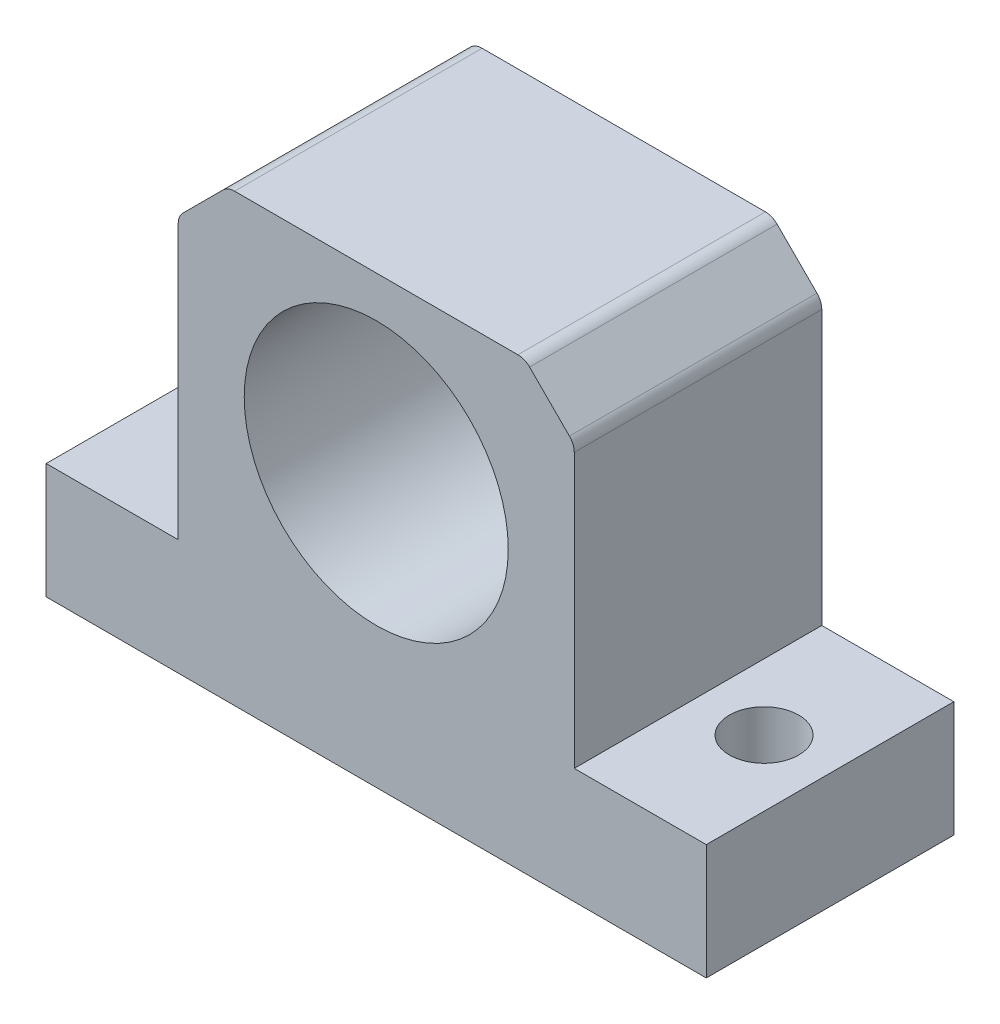
from build123d import *

# Parameters (mm, degrees)
SKETCH1_R             = 8
BOSS_EXTRUDE1_DEPTH   = 15
CHAMFER1_SIZE         = 3
SKETCH2_R             = 8
SKETCH2_R_2           = 5
BOSS_EXTRUDE2_DEPTH   = 3
M5_TAPPED_HOLE1_D     = 4.2
M5_TAPPED_HOLE1_DEPTH = 103.56
M5_TAPPED_HOLE1_TIP   = 1.2618073
FILLET1_R             = 1


with BuildPart() as part:
    # Sketch1 → Boss-Extrude1 (new body)
    with BuildSketch(Plane.XY):
        Polygon((20, 0), (-20, 0), (-20, 7), (-12, 7), (-12, 27), (12, 27), (12, 7), (20, 7), align=None)
        with Locations((0, 16.5)):
            Circle(SKETCH1_R, mode=Mode.SUBTRACT)
    extrude(amount=BOSS_EXTRUDE1_DEPTH)

    # Chamfer1
    chamfer1_edges = [part.edges().sort_by_distance(p)[0] for p in [
        (-12, 27, 7.5),
        (12, 27, 7.5),
    ]]
    chamfer(chamfer1_edges, length=CHAMFER1_SIZE)

    # Sketch2 → Boss-Extrude2 (add)
    with BuildSketch(Plane(origin=(0, 0, 0), x_dir=(-1, 0, 0), z_dir=(0, 0, -1))):
        with Locations((0, 16.5)):
            Circle(SKETCH2_R)
        with Locations((0, 16.5)):
            Circle(SKETCH2_R_2, mode=Mode.SUBTRACT)
    extrude(amount=-BOSS_EXTRUDE2_DEPTH)

    # M5 Tapped Hole1
    with Locations(Plane(origin=(-16, 0, 7.5), x_dir=(0, 0, -1), z_dir=(0, -1, 0))):
        with Locations((0, 0), (0, 32)):
            Hole(M5_TAPPED_HOLE1_D / 2, depth=M5_TAPPED_HOLE1_DEPTH)
            with Locations((0, 0, -(M5_TAPPED_HOLE1_DEPTH + M5_TAPPED_HOLE1_TIP / 2))):  # 118° drill point
                Cone(0, M5_TAPPED_HOLE1_D / 2, M5_TAPPED_HOLE1_TIP, mode=Mode.SUBTRACT)

    # Fillet1
    fillet1_edges = [part.edges().sort_by_distance(p)[0] for p in [
        (-12, 24, 7.5),
        (9, 27, 7.5),
        (-9, 27, 7.5),
        (12, 24, 7.5),
    ]]
    fillet(fillet1_edges, radius=FILLET1_R)


solid = part.part
